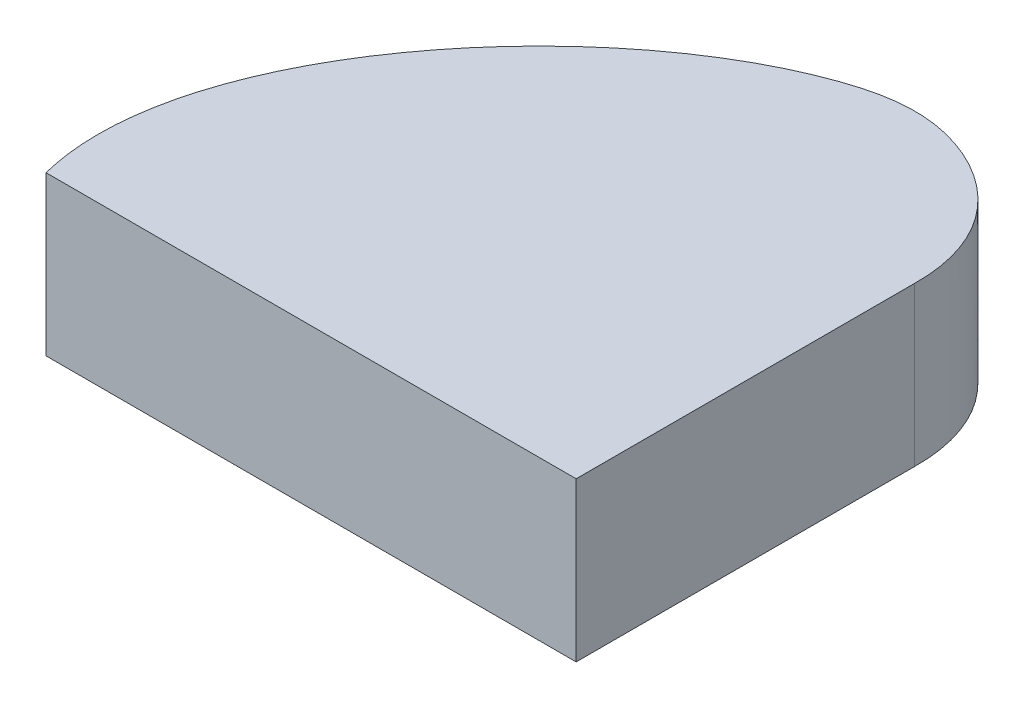
from build123d import *

# Parameters (mm, degrees)
BOSS_EXTRUDE1_DEPTH = 6.35


with BuildPart() as part:
    # Sketch1 → Boss-Extrude1 (new body)
    with BuildSketch(Plane(origin=(0, 0, 0), x_dir=(1, 0, 0), z_dir=(0, 1, 0))):
        with BuildLine():
            Line((0, 0), (21.220608204, 0))
            Line((21.220608204, 0), (21.220608204, 13.533601596))
            add(Edge.make_bspline(
                [(21.220608204, 13.533601596), (21.270255127, 17.099829109), (17.089729968, 20.071398977), (6.869360689, 18.068902738), (-1.864659781, 7.331618204), (0, 0)],
                knots=[0, 0, 0, 0, 0.200636559, 0.315852643, 1, 1, 1, 1], degree=3))
        make_face()
    extrude(amount=BOSS_EXTRUDE1_DEPTH)


solid = part.part
